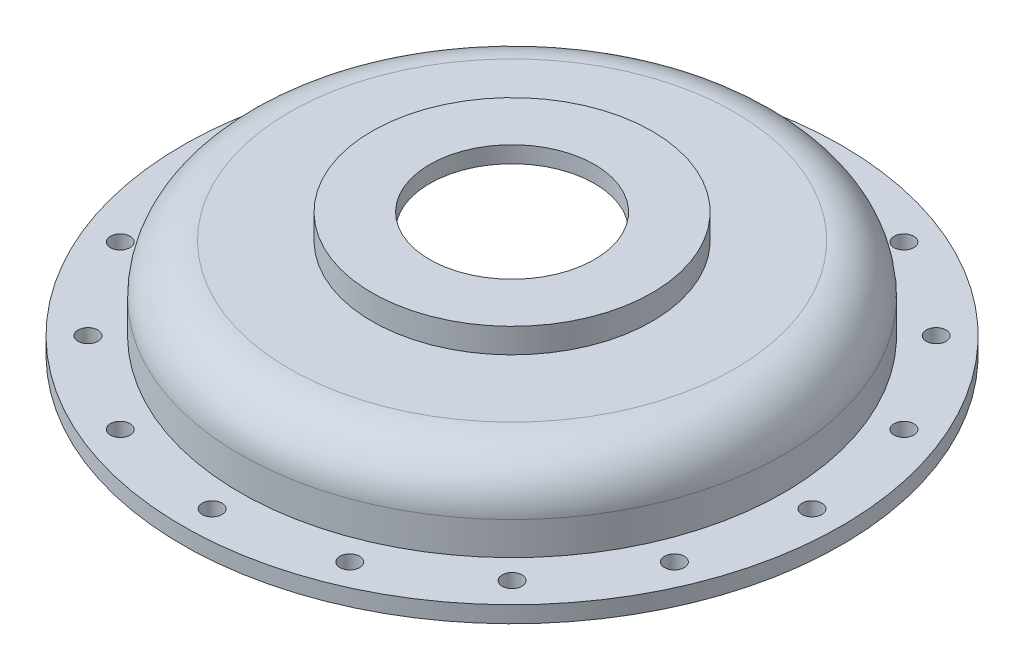
from build123d import *

# Parameters (mm, degrees)
SKETCH2_R          = 6
CUT_EXTRUDE1_DEPTH = 11
CIRPATTERN1_COUNT  = 16


with BuildPart() as part:
    # Sketch1 → Revolve1 (revolve)
    with BuildSketch(Plane.XY):
        with BuildLine():
            Line((200, 0), (200, 10))
            Line((200, 10), (165, 10))
            Line((165, 10), (165, 30))
            ThreePointArc((165, 30), (156.213203436, 51.213203436), (135, 60))
            Line((135, 60), (85, 60))
            Line((85, 60), (85, 75))
            Line((85, 75), (50, 75))
            Line((50, 75), (50, 65))
            Line((50, 65), (75, 65))
            Line((75, 65), (75, 50))
            Line((75, 50), (135, 50))
            ThreePointArc((135, 50), (149.142135624, 44.142135624), (155, 30))
            Line((155, 30), (155, 0))
            Line((155, 0), (200, 0))
        make_face()
    revolve(axis=Axis((0, 0, 0), (0, 1, 0)))

    # Sketch2 → Cut-Extrude1 (cut, through all)
    with BuildSketch(Plane(origin=(0, 10, 0), x_dir=(1, 0, 0), z_dir=(0, 1, 0))):
        with Locations((182, 0)):
            Circle(SKETCH2_R)
    cut_extrude1 = extrude(amount=-CUT_EXTRUDE1_DEPTH, mode=Mode.SUBTRACT)

    # CirPattern1: Cut-Extrude1 ×16 about axis
    cirpattern1_axis = Axis((0, 0, 0), (0, 1, 0))
    for i in range(1, CIRPATTERN1_COUNT):
        add(cut_extrude1.rotate(cirpattern1_axis, i * 360 / CIRPATTERN1_COUNT), mode=Mode.SUBTRACT)


solid = part.part
